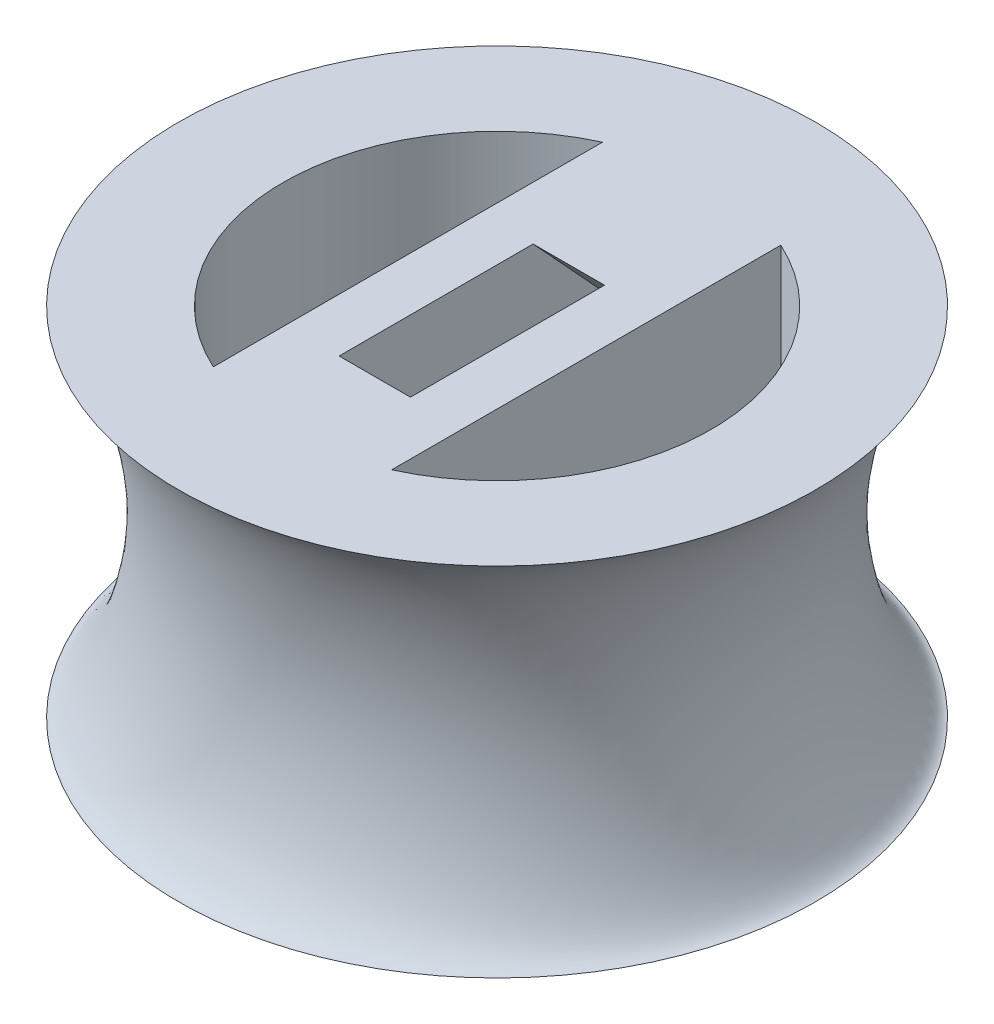
from build123d import *

# Parameters (mm, degrees)
SKETCH2_R               = 9
BOSS_EXTRUDE1_DEPTH     = 10
CUT_EXTRUDE1_DEPTH      = 11.0000001
CUT_EXTRUDE2_DEPTH      = 1
CUT_EXTRUDE2_DEPTH_BACK = 1


with BuildPart() as part:
    # Sketch2 → Boss-Extrude1 (new body)
    with BuildSketch(Plane(origin=(0, 0, 0), x_dir=(1, 0, 0), z_dir=(0, 1, 0))):
        Circle(SKETCH2_R)
    extrude(amount=BOSS_EXTRUDE1_DEPTH)

    # Sketch3 → Cut-Revolve1 (revolve, cut)
    with BuildSketch(Plane.XY):
        with BuildLine():
            Line((-9, 10), (-9, 0))
            add(Edge.make_bspline(
                [(-9, 10), (-8.339177008, 10.090505936), (-6.320822992, 5), (-8.339177008, -0.090505936), (-9, 0)],
                knots=[0, 0, 0, 0, 0.256608512, 0.513217025, 0.513217025, 0.513217025, 0.513217025], degree=3))
        make_face()
    revolve(axis=Axis((0, 0, 0), (0, 1, 0)), mode=Mode.SUBTRACT)

    # Sketch4 → Cut-Extrude1 (cut, through all)
    with BuildSketch(Plane(origin=(0, 10, 0), x_dir=(1, 0, 0), z_dir=(0, 1, 0))):
        with BuildLine():
            ThreePointArc((-6, 0), (-5.049752469, -3.240370349), (-2.5, -5.454356057))
            Line((-2.5, -5.454356057), (-2.5, 0))
            Line((-2.5, 0), (-6, 0))
        make_face()
        with BuildLine():
            Line((-6, 0), (-2.5, 0))
            Line((-2.5, 0), (-2.5, 5.454356057))
            ThreePointArc((-2.5, 5.454356057), (-5.049752469, 3.240370349), (-6, 0))
        make_face()
        with BuildLine():
            Line((2.5, 0), (2.5, -5.454356057))
            ThreePointArc((2.5, -5.454356057), (5.049752469, -3.240370349), (6, 0))
            Line((6, 0), (2.5, 0))
        make_face()
        with BuildLine():
            Line((2.5, 5.454356057), (2.5, 0))
            Line((2.5, 0), (6, 0))
            ThreePointArc((6, 0), (5.049752469, 3.240370349), (2.5, 5.454356057))
        make_face()
    extrude(amount=-CUT_EXTRUDE1_DEPTH, mode=Mode.SUBTRACT)

    # Sketch5 → Cut-Extrude2 (cut, two sides)
    with BuildSketch(Plane.ZY) as cut_extrude2_sk:
        with BuildLine():
            Line((-2.01113744, 10), (-4.520166387, 7.276604619))
            ThreePointArc((-4.520166387, 7.276604619), (-4.783869038, 6.55810107), (-4.462276239, 5.863576406))
            Line((-4.462276239, 5.863576406), (-2.991357878, 4.508438341))
            ThreePointArc((-2.991357878, 4.508438341), (-2.272854329, 4.24473569), (-1.578329665, 4.566328489))
            Line((-1.578329665, 4.566328489), (3.427641633, 10))
            Line((3.427641633, 10), (-2.01113744, 10))
        make_face()
    extrude(amount=CUT_EXTRUDE2_DEPTH, mode=Mode.SUBTRACT)
    extrude(cut_extrude2_sk.sketch, amount=-CUT_EXTRUDE2_DEPTH_BACK, mode=Mode.SUBTRACT)


solid = part.part
